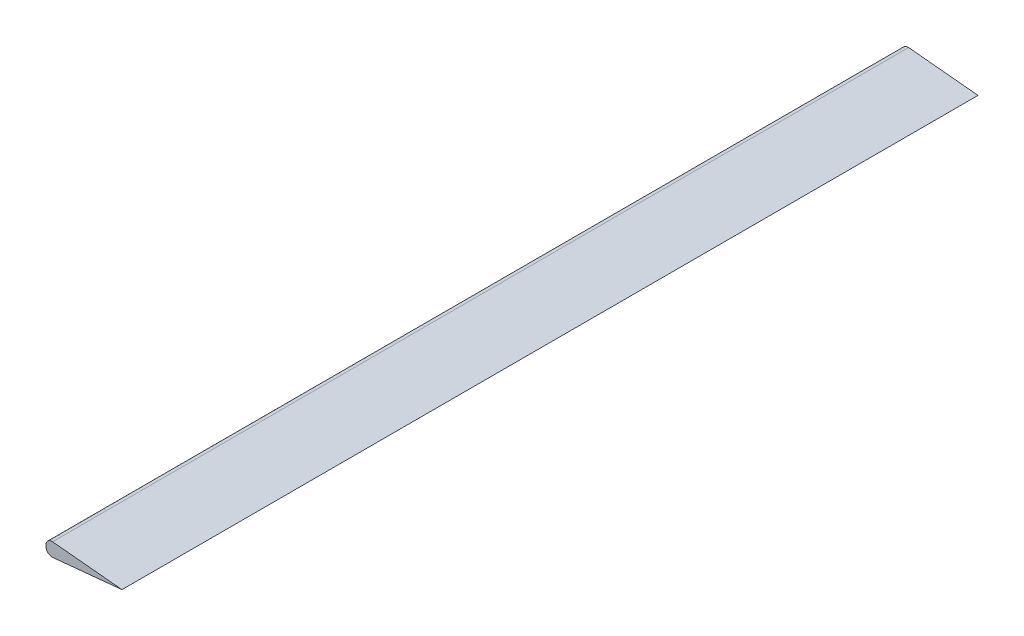
from build123d import *

# Parameters (mm, degrees)
BOSS_EXTRUDE1_DEPTH = 542.544
FILLET1_R           = 3.81


with BuildPart() as part:
    # Sketch1 → Boss-Extrude1 (new body)
    with BuildSketch(Plane.XY):
        Polygon((0, 4.68249), (0, -4.68249), (48.14824, 0), align=None)
    extrude(amount=BOSS_EXTRUDE1_DEPTH)

    # Fillet1
    fillet1_edges = [part.edges().sort_by_distance(p)[0] for p in [
        (0, -4.68249, 271.272),
        (0, 4.68249, 271.272),
    ]]
    fillet(fillet1_edges, radius=FILLET1_R)


solid = part.part
